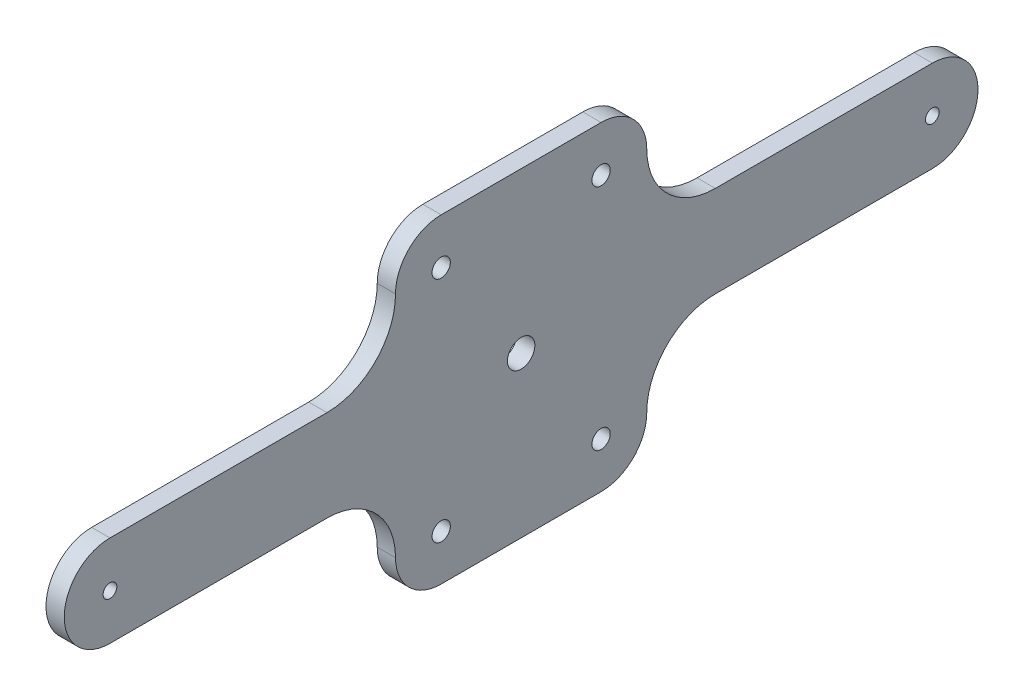
from build123d import *

# Parameters (mm, degrees)
SKETCH1_W               = 210
SKETCH1_H               = 75
BOSS_EXTRUDE1_DEPTH     = 4
SKETCH2_R               = 1.5
CUT_EXTRUDE1_DEPTH      = 5
SKETCH3_R               = 2
CUT_EXTRUDE2_DEPTH      = 5
CUT_EXTRUDE3_DEPTH      = 5
MIRROR3_COPY_1_SKETCH_R = 2
MIRROR3_COPY_1_DEPTH    = 5
MIRROR3_COPY_2_DEPTH    = 5
SKETCH5_R               = 3
CUT_EXTRUDE4_DEPTH      = 5


with BuildPart() as part:
    # Sketch1 → Boss-Extrude1 (new body)
    with BuildSketch(Plane(origin=(0, 0, 0), x_dir=(0, 0, -1), z_dir=(1, 0, 0))):
        Rectangle(SKETCH1_W, SKETCH1_H)
    extrude(amount=BOSS_EXTRUDE1_DEPTH)

    # Sketch2 → Cut-Extrude1 (cut, through all)
    with BuildSketch(Plane(origin=(4, 0, 0), x_dir=(0, 0, -1), z_dir=(1, 0, 0))):
        with Locations((-90, 0)):
            Circle(SKETCH2_R)
    cut_extrude1 = extrude(amount=-CUT_EXTRUDE1_DEPTH, mode=Mode.SUBTRACT)

    # Sketch3 → Cut-Extrude2 (cut, through all)
    with BuildSketch(Plane(origin=(4, 0, 0), x_dir=(0, 0, -1), z_dir=(1, 0, 0))):
        with Locations((-17.5, 25)):
            Circle(SKETCH3_R)
    cut_extrude2 = extrude(amount=-CUT_EXTRUDE2_DEPTH, mode=Mode.SUBTRACT)

    # Sketch4 → Cut-Extrude3 (cut, through all)
    with BuildSketch(Plane(origin=(4, 0, 0), x_dir=(0, 0, -1), z_dir=(1, 0, 0))):
        with BuildLine():
            Line((-105, 0), (-105, 37.5))
            Line((-105, 37.5), (0, 37.5))
            Line((0, 37.5), (0, 35))
            Line((0, 35), (-17.5, 35))
            ThreePointArc((-17.5, 35), (-24.571067812, 32.071067812), (-27.5, 25))
            ThreePointArc((-27.5, 25), (-31.893398282, 14.393398282), (-42.5, 10))
            Line((-42.5, 10), (-90, 10))
            ThreePointArc((-90, 10), (-97.071067812, 7.071067812), (-100, 0))
            Line((-100, 0), (-105, 0))
        make_face()
    cut_extrude3 = extrude(amount=-CUT_EXTRUDE3_DEPTH, mode=Mode.SUBTRACT)

    # Mirror2: Cut-Extrude2, Cut-Extrude3 across plane
    add(cut_extrude2.mirror(Plane.ZX), mode=Mode.SUBTRACT)
    add(cut_extrude3.mirror(Plane.ZX), mode=Mode.SUBTRACT)

    # Mirror3: Cut-Extrude3, Cut-Extrude1, Cut-Extrude2 across plane
    add(cut_extrude3.mirror(Plane.XY), mode=Mode.SUBTRACT)
    add(cut_extrude1.mirror(Plane.XY), mode=Mode.SUBTRACT)
    add(cut_extrude2.mirror(Plane.XY), mode=Mode.SUBTRACT)

    # Mirror3 copy 1 sketch → Mirror3 copy 1 (cut, through all)
    with BuildSketch(Plane(origin=(4, 0, 0), x_dir=(0, 0, 1), z_dir=(1, 0, 0))):
        with Locations((-17.5, 25)):
            Circle(MIRROR3_COPY_1_SKETCH_R)
    extrude(amount=-MIRROR3_COPY_1_DEPTH, mode=Mode.SUBTRACT)

    # Mirror3 copy 2 sketch → Mirror3 copy 2 (cut, through all)
    with BuildSketch(Plane(origin=(4, 0, 0), x_dir=(0, 0, 1), z_dir=(1, 0, 0))):
        with BuildLine():
            Line((-105, 0), (-105, 37.5))
            Line((-105, 37.5), (0, 37.5))
            Line((0, 37.5), (0, 35))
            Line((0, 35), (-17.5, 35))
            ThreePointArc((-17.5, 35), (-24.571067812, 32.071067812), (-27.5, 25))
            ThreePointArc((-27.5, 25), (-31.893398282, 14.393398282), (-42.5, 10))
            Line((-42.5, 10), (-90, 10))
            ThreePointArc((-90, 10), (-97.071067812, 7.071067812), (-100, 0))
            Line((-100, 0), (-105, 0))
        make_face()
    extrude(amount=-MIRROR3_COPY_2_DEPTH, mode=Mode.SUBTRACT)

    # Sketch5 → Cut-Extrude4 (cut, through all)
    with BuildSketch(Plane(origin=(4, 0, 0), x_dir=(0, 0, -1), z_dir=(1, 0, 0))):
        Circle(SKETCH5_R)
    extrude(amount=-CUT_EXTRUDE4_DEPTH, mode=Mode.SUBTRACT)


solid = part.part
